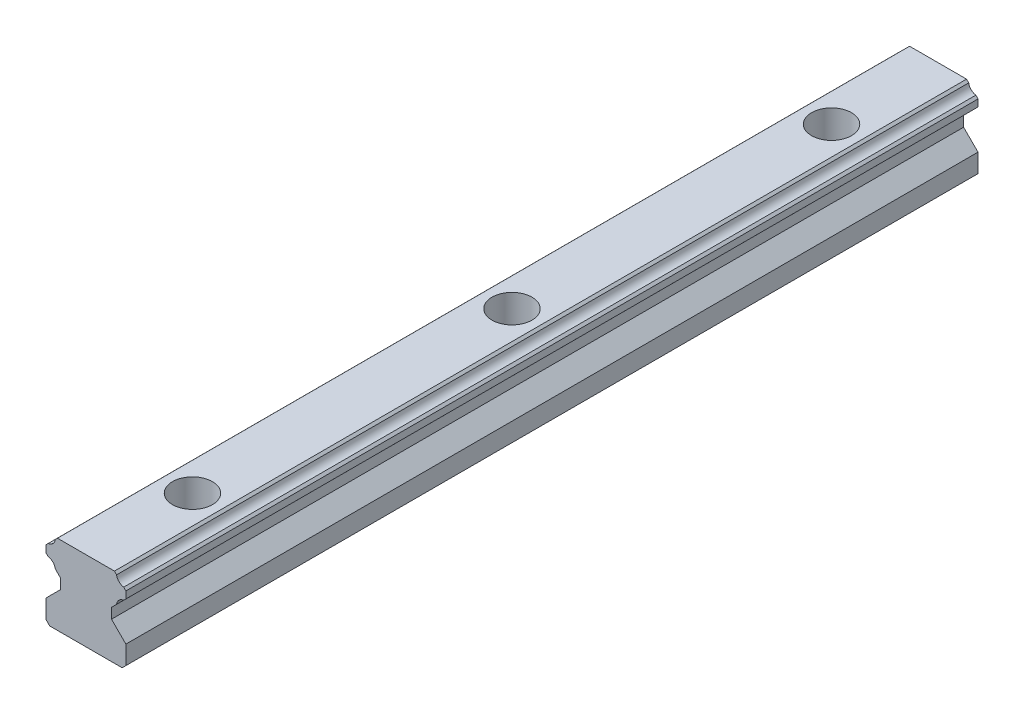
from build123d import *

# Parameters (mm, degrees)
EXTRUDE1_DEPTH  = 160
LPATTERN1_COUNT = 3
LPATTERN1_PITCH = 60


with BuildPart() as part:
    # Sketch1 → Extrude1 (new body)
    with BuildSketch(Plane(origin=(-20, 0, 0), x_dir=(1, 0, 0), z_dir=(0, 0, 1))):
        with BuildLine():
            Line((12.5, 0.69999271), (13.199992786, 0))
            Line((13.199992786, 0), (26.800007214, 0))
            Line((26.800007214, 0), (27.5, 0.69999271))
            Line((27.5, 0.69999271), (27.5, 4.2000246))
            Line((27.5, 4.2000246), (24.8000183, 6.9000063))
            Line((24.8000183, 6.9000063), (24.8000183, 8.8400054))
            Line((24.8000183, 8.8400054), (25.755946813, 9.794179118))
            ThreePointArc((25.755946813, 9.794179118), (26.198484624, 10.690600567), (27.09432569, 11.13431209))
            Line((27.09432569, 11.13431209), (27.5, 11.5399866))
            Line((27.5, 11.5399866), (27.5, 12.8500204))
            Line((27.5, 12.8500204), (27.09432569, 13.268442751))
            ThreePointArc((27.09432569, 13.268442751), (26.202460867, 13.706434947), (25.755946813, 14.594063938))
            Line((25.755946813, 14.594063938), (25.3500197, 15))
            Line((25.3500197, 15), (14.6499803, 15))
            Line((14.6499803, 15), (14.244053187, 14.594063938))
            ThreePointArc((14.244053187, 14.594063938), (13.797539133, 13.706434947), (12.90567431, 13.268442751))
            Line((12.90567431, 13.268442751), (12.5, 12.8500204))
            Line((12.5, 12.8500204), (12.5, 11.5399866))
            Line((12.5, 11.5399866), (12.90567431, 11.13431209))
            ThreePointArc((12.90567431, 11.13431209), (13.801515376, 10.690600567), (14.244053187, 9.794179118))
            Line((14.244053187, 9.794179118), (15.1999817, 8.8400054))
            Line((15.1999817, 8.8400054), (15.1999817, 6.9000063))
            Line((15.1999817, 6.9000063), (12.5, 4.2000246))
            Line((12.5, 4.2000246), (12.5, 0.69999271))
        make_face()
    extrude(amount=-EXTRUDE1_DEPTH)

    # Sketch2 → Cut-Revolve1 (revolve, cut)
    with BuildSketch(Plane(origin=(0, 0, 0), x_dir=(0, 0, -1), z_dir=(1, 0, 0))):
        Polygon((20, 15), (23.75, 15), (23.75, 9.7), (22.25, 9.7), (22.25, 0), (20, 0), align=None)
    cut_revolve1 = revolve(axis=Axis((0, 0, -20), (0, 1, 0)), mode=Mode.SUBTRACT)

    # LPattern1: Cut-Revolve1 ×3
    with Locations(*[(0, 0, -i * LPATTERN1_PITCH) for i in range(1, LPATTERN1_COUNT)]):
        add(cut_revolve1, mode=Mode.SUBTRACT)


solid = part.part
